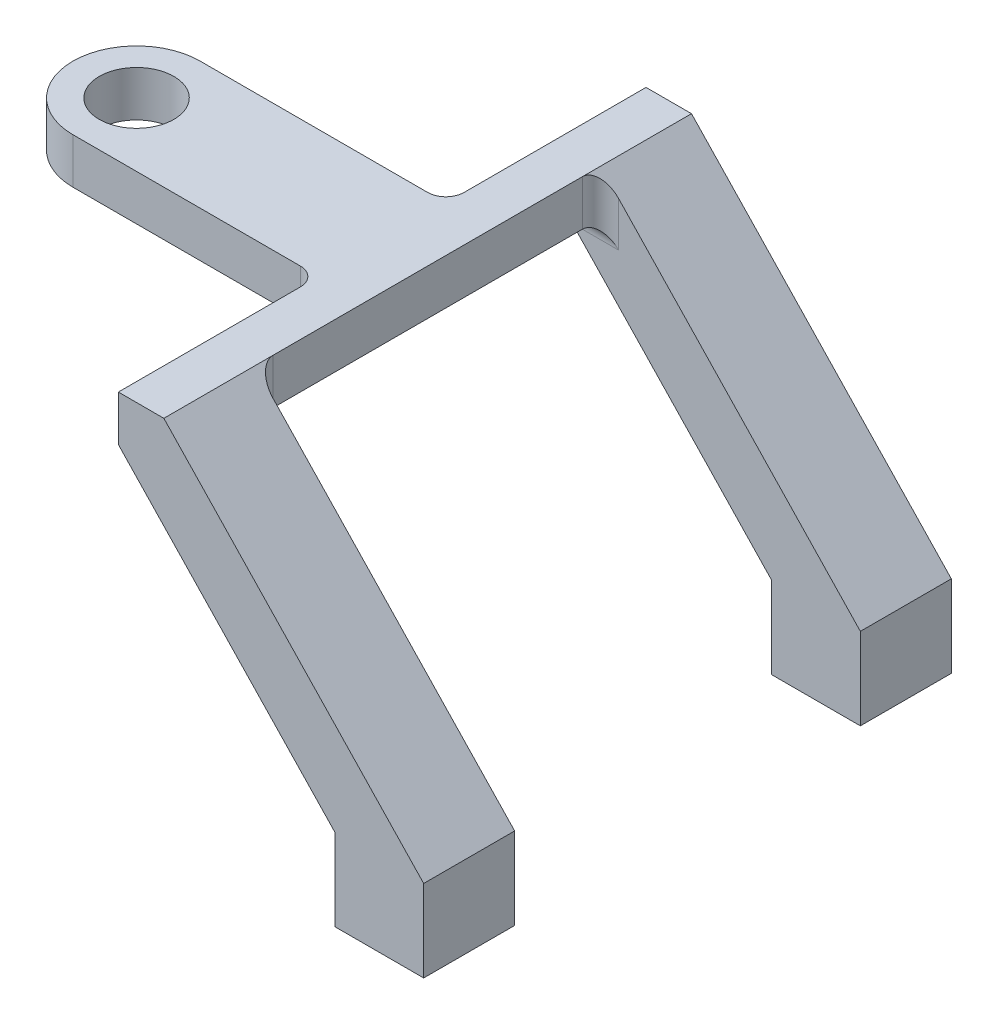
from build123d import *

# Parameters (mm, degrees)
BOSS_EXTRUDE1_DEPTH = 12.7
SKETCH2_W           = 6.35
SKETCH2_H           = 6.35
BOSS_EXTRUDE2_DEPTH = 48.26
BOSS_EXTRUDE3_DEPTH = 12.7
SKETCH4_R           = 5.207
BOSS_EXTRUDE4_DEPTH = 6.35
FILLET1_R           = 2.54


with BuildPart() as part:
    # Sketch1 → Boss-Extrude1 (new body)
    with BuildSketch(Plane.XY):
        Polygon((0, 0), (-12.3952, 0), (-12.3952, 11.43), (-42.6212, 43.18), (-42.6212, 49.53), (-36.2712, 49.53), (0, 11.43), align=None)
    extrude(amount=BOSS_EXTRUDE1_DEPTH)

    # Sketch2 → Boss-Extrude2 (add)
    with BuildSketch(Plane.XY.offset(12.7)):
        with Locations((-39.4462, 46.355)):
            Rectangle(SKETCH2_W, SKETCH2_H)
    extrude(amount=BOSS_EXTRUDE2_DEPTH)

    # Sketch3 → Boss-Extrude3 (add)
    with BuildSketch(Plane.XY.offset(60.96)):
        Polygon((-42.6212, 43.18), (-12.3952, 11.43), (-12.3952, 0), (0, 0), (0, 11.43), (-36.2712, 49.53), (-42.6212, 49.53), align=None)
    extrude(amount=BOSS_EXTRUDE3_DEPTH)

    # Sketch4 → Boss-Extrude4 (add)
    with BuildSketch(Plane(origin=(0, 49.53, 0), x_dir=(1, 0, 0), z_dir=(0, 1, 0))):
        with BuildLine():
            Line((-42.6212, -27.94), (-76.9112, -27.94))
            ThreePointArc((-76.9112, -27.94), (-85.8012, -36.83), (-76.9112, -45.72))
            Line((-76.9112, -45.72), (-42.6212, -45.72))
            Line((-42.6212, -45.72), (-42.6212, -27.94))
        make_face()
        with Locations((-76.9112, -36.83)):
            Circle(SKETCH4_R, mode=Mode.SUBTRACT)
    extrude(amount=-BOSS_EXTRUDE4_DEPTH)

    # Fillet1
    fillet1_edges = [part.edges().sort_by_distance(p)[0] for p in [
        (-39.4462, 43.18, 12.7),
        (-36.2712, 46.355, 12.7),
        (-39.4462, 43.18, 60.96),
        (-36.2712, 46.355, 60.96),
        (-42.6212, 46.355, 45.72),
        (-42.6212, 46.355, 27.94),
    ]]
    fillet(fillet1_edges, radius=FILLET1_R)


solid = part.part
